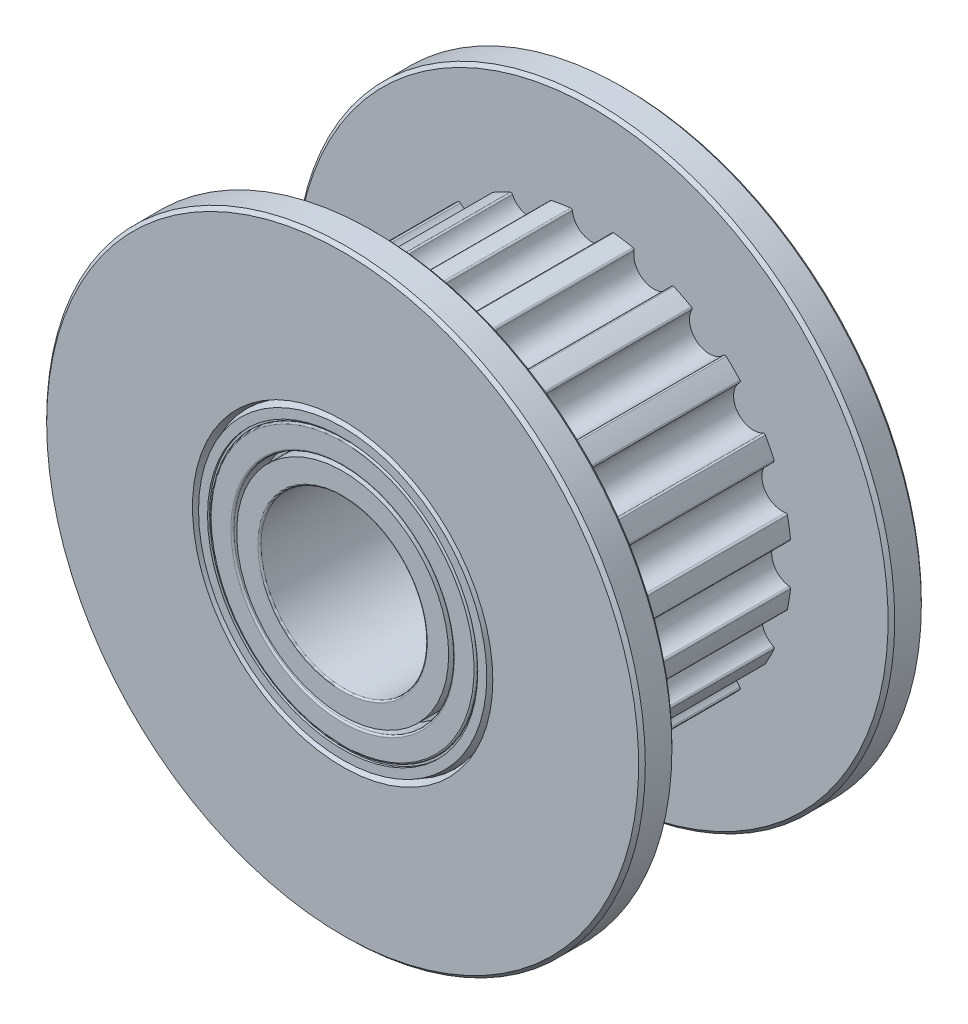
from build123d import *

# Parameters (mm, degrees)
CUT_EXTRUDE1_REACH             = 15.419
CUT_EXTRUDE1_DIRECTION_2_REACH = 15.419
FILLET1_R                      = 0.05
CIRPATTERN3_COUNT              = 20
FILLET1_OF_CIRPATTERN3_R       = 0.05
CHAMFER1_SIZE                  = 0.1
FILLET2_R                      = 0.05


with BuildPart() as part:
    # Sketch2 → Revolve1 (revolve)
    with BuildSketch(Plane(origin=(0, 0, 0), x_dir=(0, 0, -1), z_dir=(1, 0, 0))):
        Polygon((4.25, 2.5), (0, 2.5), (0, 4), (4.25, 4), (4.25, 3.3125), (3.5625, 3.3125), (3.5625, 3.1875), (3.90625, 3.1875), (4.25, 3.1875), align=None)
    revolve(axis=Axis((0, 0, 4.25), (0, 0, -1)))

    # Mirror1: part across plane


with BuildPart() as part_1:
    add(part.part)
    add(part.part.mirror(Plane.XY))

    # Fillet2
    fillet2_edges = [part_1.edges().sort_by_distance(p)[0] for p in [
        (0, -4, 4.25),
        (0, -3.3125, 4.25),
        (0, -2.5, 4.25),
        (0, -2.5, -4.25),
        (0, -4, -4.25),
        (0, -3.3125, -4.25),
        (0, -3.1875, -4.25),
    ]]
    fillet(fillet2_edges, radius=FILLET2_R)


with BuildPart() as body_2:
    # Sketch3 → Revolve2 (revolve)
    with BuildSketch(Plane(origin=(0, 0, 0), x_dir=(0, 0, -1), z_dir=(1, 0, 0))):
        Polygon((3.25, 9), (4.25, 9), (4.25, 4.51531845), (4, 4.424325892), (4.25, 4.333333333), (4.25, 4.0625), (4.1875, 4.0625), (4.1875, 4), (-4.1875, 4), (-4.1875, 4.0625), (-4.25, 4.0625), (-4.25, 4.333333333), (-4, 4.424325892), (-4.25, 4.51531845), (-4.25, 9), (-3.25, 9), (-3.25, 6), (3.25, 6), align=None)
    revolve(axis=Axis((0, 0, 4.25), (0, 0, -1)))

    # Cut-Extrude1: up to this face of the body (flat: up to its plane)
    cut_extrude1_end = Plane(body_2.part.faces().sort_by_distance((0, -6.254558441, -3.25))[0])
    # Sketch4 → Cut-Extrude1 (cut, up to the picked face)
    with BuildSketch(Plane.XY, mode=Mode.PRIVATE) as cut_extrude1_sk1:
        with BuildLine():
            Line((-0.6, 6), (0.6, 6))
            ThreePointArc((0.6, 6), (0, 5.4), (-0.6, 6))
        make_face()
    cut_extrude1_tool1 = split(extrude(cut_extrude1_sk1.sketch, amount=-CUT_EXTRUDE1_REACH, mode=Mode.PRIVATE), bisect_by=cut_extrude1_end, keep=Keep.BOTH, mode=Mode.PRIVATE)
    cut_extrude1 = cut_extrude1_tool1.solids().sort_by(Axis((0, 5.745352, 0), (0, 0, -1)))[0]
    add(cut_extrude1, mode=Mode.SUBTRACT)

    # Cut-Extrude1 direction 2: up to this face of the body (flat: up to its plane)
    cut_extrude1_direction_2_end = Plane(body_2.part.faces().sort_by_distance((0, -8.745441559, 3.25))[0])
    # Sketch4 → Cut-Extrude1 direction 2 (cut, up to the picked face)
    with BuildSketch(Plane.XY, mode=Mode.PRIVATE) as cut_extrude1_direction_2_sk1:
        with BuildLine():
            Line((-0.6, 6), (0.6, 6))
            ThreePointArc((0.6, 6), (0, 5.4), (-0.6, 6))
        make_face()
    cut_extrude1_direction_2_tool1 = split(extrude(cut_extrude1_direction_2_sk1.sketch, amount=CUT_EXTRUDE1_DIRECTION_2_REACH, mode=Mode.PRIVATE), bisect_by=cut_extrude1_direction_2_end, keep=Keep.BOTH, mode=Mode.PRIVATE)
    cut_extrude1_direction_2 = cut_extrude1_direction_2_tool1.solids().sort_by(Axis((0, 5.745352, 0), (0, 0, 1)))[0]
    add(cut_extrude1_direction_2, mode=Mode.SUBTRACT)

    # Fillet1
    fillet1_edges = [body_2.edges().sort_by_distance(p)[0] for p in [
        (0.599249531, 5.97, 0),
        (-0.599249531, 5.97, 0),
    ]]
    fillet(fillet1_edges, radius=FILLET1_R)

    # CirPattern3: Cut-Extrude1, Cut-Extrude1 direction 2 ×20 about axis
    cirpattern3_axis = Axis((0, 0, -3.25), (0, 0, 1))
    add([cut_extrude1.rotate(cirpattern3_axis, i * 360 / CIRPATTERN3_COUNT) for i in range(1, CIRPATTERN3_COUNT)], mode=Mode.SUBTRACT)
    add([cut_extrude1_direction_2.rotate(cirpattern3_axis, i * 360 / CIRPATTERN3_COUNT) for i in range(1, CIRPATTERN3_COUNT)], mode=Mode.SUBTRACT)

    # Fillet1 of CirPattern3
    fillet1_of_cirpattern3_edges = [body_2.edges().sort_by_distance(p)[0] for p in [
        (-1.274911285, 5.862985691, 0),
        (-2.414751627, 5.492629113, 0),
        (-3.024274902, 5.182061493, 0),
        (-3.99388101, 4.47760142, 0),
        (-4.47760142, 3.99388101, 0),
        (-5.182061493, 3.024274902, 0),
        (-5.492629113, 2.414751627, 0),
        (-5.862985691, 1.274911285, 0),
        (-5.97, 0.599249531, 0),
        (-5.97, -0.599249531, 0),
        (-5.862985691, -1.274911285, 0),
        (-5.492629113, -2.414751627, 0),
        (-5.182061493, -3.024274902, 0),
        (-4.47760142, -3.99388101, 0),
        (-3.99388101, -4.47760142, 0),
        (-3.024274902, -5.182061493, 0),
        (-2.414751627, -5.492629113, 0),
        (-1.274911285, -5.862985691, 0),
        (-0.599249531, -5.97, 0),
        (0.599249531, -5.97, 0),
        (1.274911285, -5.862985691, 0),
        (2.414751627, -5.492629113, 0),
        (3.024274902, -5.182061493, 0),
        (3.99388101, -4.47760142, 0),
        (4.47760142, -3.99388101, 0),
        (5.182061493, -3.024274902, 0),
        (5.492629113, -2.414751627, 0),
        (5.862985691, -1.274911285, 0),
        (5.97, -0.599249531, 0),
        (5.97, 0.599249531, 0),
        (5.862985691, 1.274911285, 0),
        (5.492629113, 2.414751627, 0),
        (5.182061493, 3.024274902, 0),
        (4.47760142, 3.99388101, 0),
        (3.99388101, 4.47760142, 0),
        (3.024274902, 5.182061493, 0),
        (2.414751627, 5.492629113, 0),
        (1.274911285, 5.862985691, 0),
    ]]
    fillet(fillet1_of_cirpattern3_edges, radius=FILLET1_OF_CIRPATTERN3_R)

    # Chamfer1
    chamfer1_edges = [body_2.edges().sort_by_distance(p)[0] for p in [
        (0, -9, -4.25),
        (0, -9, -3.25),
        (0, -9, 3.25),
        (0, -9, 4.25),
    ]]
    chamfer(chamfer1_edges, length=CHAMFER1_SIZE)

    # Combine1: union part
    add(part_1.part)


solid = body_2.part
